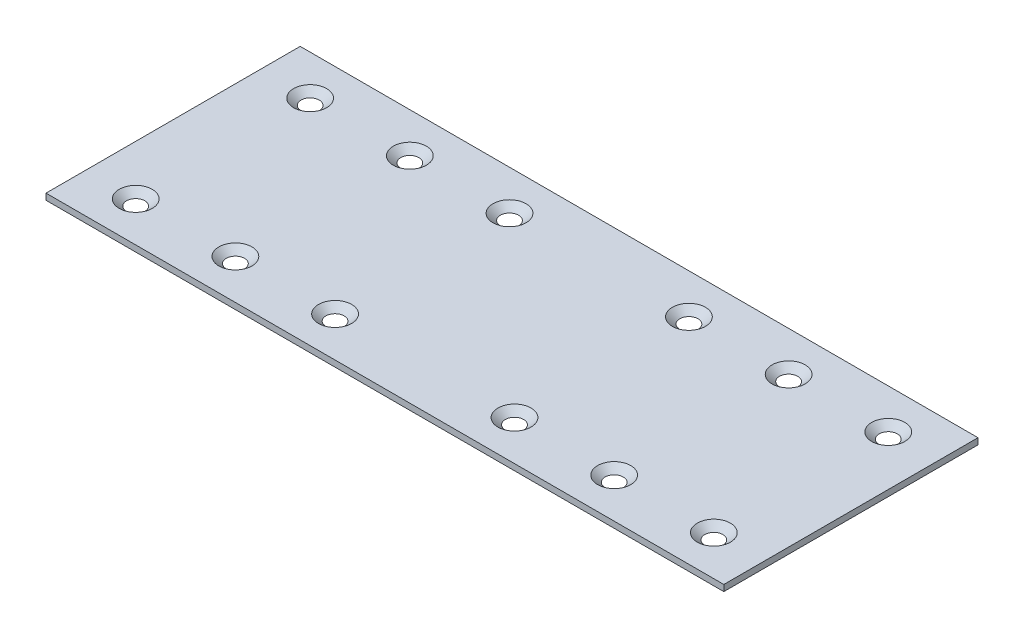
from build123d import *

# Parameters (mm, degrees)
SKETCH1_W                                         = 172.72
SKETCH1_H                                         = 64.77
BOSS_EXTRUDE1_DEPTH                               = 1.5875
CSK_FOR_8_FLAT_HEAD_MACHINE_SCREW_100_D           = 4.4958
CSK_FOR_8_FLAT_HEAD_MACHINE_SCREW_100_DEPTH       = 12.7
CSK_FOR_8_FLAT_HEAD_MACHINE_SCREW_100_CSINK_D     = 8.4328
CSK_FOR_8_FLAT_HEAD_MACHINE_SCREW_100_CSINK_ANGLE = 100
CSK_FOR_8_FLAT_HEAD_MACHINE_SCREW_100_TIP         = 1.350674586


with BuildPart() as part:
    # Sketch1 → Boss-Extrude1 (new body)
    with BuildSketch(Plane(origin=(0, 0, 0), x_dir=(1, 0, 0), z_dir=(0, 1, 0))):
        with Locations((86.36, 32.385)):
            Rectangle(SKETCH1_W, SKETCH1_H)
    extrude(amount=BOSS_EXTRUDE1_DEPTH)

    # CSK for #8 Flat Head Machine Screw (100)1
    with Locations(Plane(origin=(0, 1.5875, 0), x_dir=(1, 0, 0), z_dir=(0, 1, 0))):
        with Locations((12.7, 54.61), (38.1, 54.61), (63.5, 54.61), (109.22, 54.61), (134.62, 54.61), (160.02, 54.61), (160.02, 10.16), (134.62, 10.16), (109.22, 10.16), (63.5, 10.16), (38.1, 10.16), (12.7, 10.16)):
            CounterSinkHole(CSK_FOR_8_FLAT_HEAD_MACHINE_SCREW_100_D / 2, CSK_FOR_8_FLAT_HEAD_MACHINE_SCREW_100_CSINK_D / 2, depth=CSK_FOR_8_FLAT_HEAD_MACHINE_SCREW_100_DEPTH, counter_sink_angle=CSK_FOR_8_FLAT_HEAD_MACHINE_SCREW_100_CSINK_ANGLE)
            with Locations((0, 0, -(CSK_FOR_8_FLAT_HEAD_MACHINE_SCREW_100_DEPTH + CSK_FOR_8_FLAT_HEAD_MACHINE_SCREW_100_TIP / 2))):  # 118° drill point
                Cone(0, CSK_FOR_8_FLAT_HEAD_MACHINE_SCREW_100_D / 2, CSK_FOR_8_FLAT_HEAD_MACHINE_SCREW_100_TIP, mode=Mode.SUBTRACT)


solid = part.part
